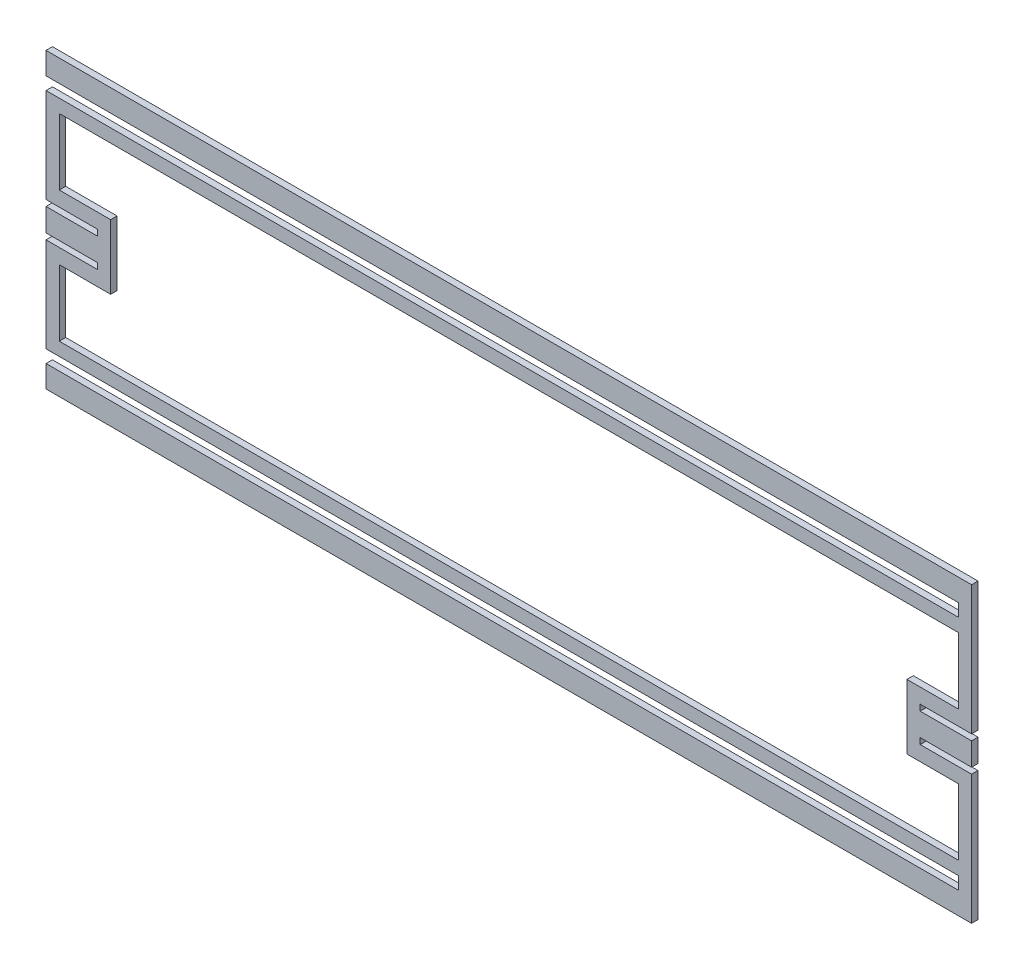
from build123d import *

# Parameters (mm, degrees)
BOSS_EXTRUDE1_DEPTH = 3.175


with BuildPart() as part:
    # Sketch1 → Boss-Extrude1 (new body)
    with BuildSketch(Plane.XY):
        Polygon((-228.7016, 8.62965), (-203.3016, 8.62965), (-203.3016, 5.65785), (-228.7016, 5.65785), (-228.7016, -5.65785), (-203.3016, -5.65785), (-203.3016, -8.62965), (-228.7016, -8.62965), (-228.7016, -55.273575), (222.1484, -55.273575), (222.1484, -61.547375), (-228.7016, -61.547375), (-228.7016, -72.4662), (228.7016, -72.4662), (228.7016, -8.62965), (203.3016, -8.62965), (203.3016, -5.65785), (228.7016, -5.65785), (228.7016, 5.65785), (203.3016, 5.65785), (203.3016, 8.62965), (228.7016, 8.62965), (228.7016, 72.4662), (-228.7016, 72.4662), (-228.7016, 61.547375), (222.1484, 61.547375), (222.1484, 55.273575), (-228.7016, 55.273575), align=None)
        Polygon((222.1484, -48.720375), (222.1484, -15.9766), (196.7484, -15.9766), (196.7484, 15.9766), (222.1484, 15.9766), (222.1484, 48.720375), (-222.1484, 48.720375), (-222.1484, 15.9766), (-196.7484, 15.9766), (-196.7484, -15.9766), (-222.1484, -15.9766), (-222.1484, -48.720375), align=None, mode=Mode.SUBTRACT)
    extrude(amount=BOSS_EXTRUDE1_DEPTH)


solid = part.part
